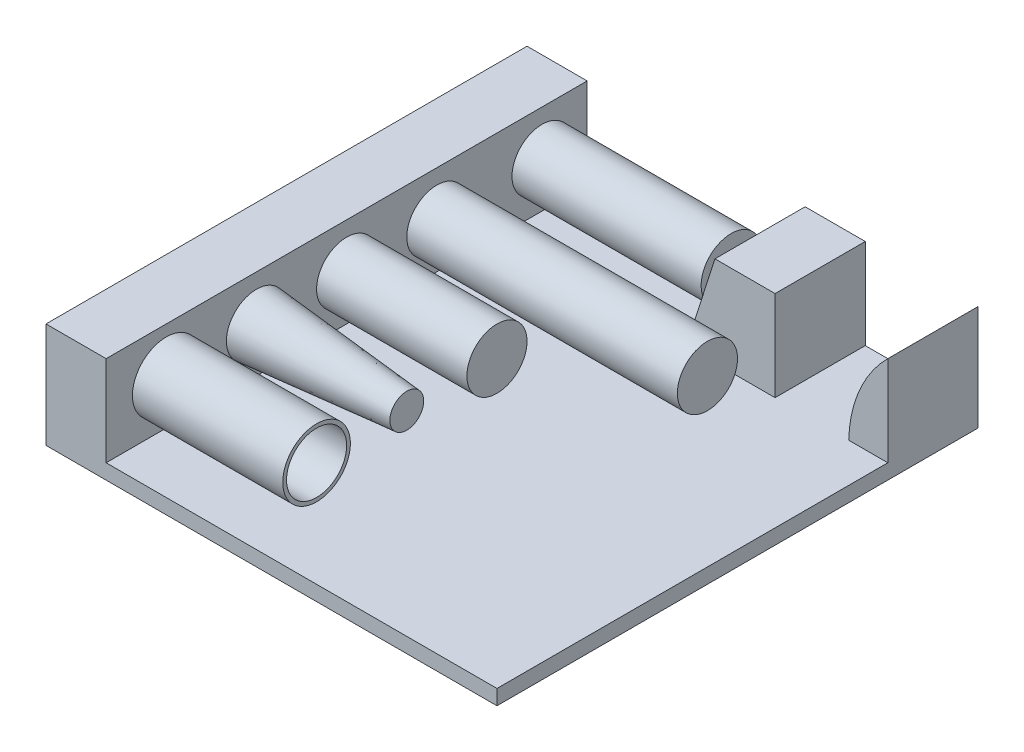
from build123d import *

# Parameters (mm, degrees)
BOSS_EXTRUDE1_DEPTH             = 640
BOSS_EXTRUDE2_DEPTH             = 120
ONE_SIDE_R                      = 40
BOSS_EXTRUDE4_DEPTH             = 251.6
BOTH_SIDES_R                    = 40
BOSS_EXTRUDE5_DEPTH             = 200
BOSS_EXTRUDE5_DIRECTION_2_REACH = 242
SOLID_2_R                       = 40
BOSS_EXTRUDE6_DEPTH             = 200
DRAFT_2_R                       = 40
BOSS_EXTRUDE7_DEPTH             = 200
BOSS_EXTRUDE7_TAPER             = 5
THICKEN_2_R                     = 45
THICKEN_2_R_2                   = 40
EXTRUDE_THIN1_DEPTH             = 200


with BuildPart() as part:
    # Sketch1 → Boss-Extrude1 (new body)
    with BuildSketch(Plane.XY):
        Polygon((-300, 0), (300, 0), (300, 20), (-220, 20), (-220, 140), (-300, 140), align=None)
    extrude(amount=BOSS_EXTRUDE1_DEPTH)

    # Sketch2 → Boss-Extrude2 (add)
    with BuildSketch(Plane.XY):
        with BuildLine():
            Line((300, 140), (300, 20))
            Line((300, 20), (247.956312481, 20))
            ThreePointArc((247.956312481, 20), (262.414199332, 85.015257999), (300, 140))
        make_face()
        Polygon((150, 140), (70, 140), (31.6, 20), (150, 20), align=None)
    extrude(amount=BOSS_EXTRUDE2_DEPTH)

    # One_Side → Boss-Extrude4 (add)
    with BuildSketch(Plane(origin=(-220, 0, 0), x_dir=(0, 0, -1), z_dir=(1, 0, 0))):
        with Locations((-60, 80)):
            Circle(ONE_SIDE_R)
    extrude(amount=BOSS_EXTRUDE4_DEPTH)

    # Both_Sides → Boss-Extrude5 (add)
    with BuildSketch(Plane(origin=(-60, 0, 0), x_dir=(0, 0, -1), z_dir=(1, 0, 0))):
        with Locations((-200, 80)):
            Circle(BOTH_SIDES_R)
    extrude(amount=BOSS_EXTRUDE5_DEPTH)

    # Both_Sides → Boss-Extrude5 direction 2 (add, up to next)
    with BuildSketch(Plane(origin=(-60, 0, 0), x_dir=(0, 0, -1), z_dir=(1, 0, 0)), mode=Mode.PRIVATE) as boss_extrude5_direction_2_sk1:
        with Locations((-200, 80)):
            Circle(BOTH_SIDES_R)
    boss_extrude5_direction_2_tool1 = extrude(boss_extrude5_direction_2_sk1.sketch, amount=-BOSS_EXTRUDE5_DIRECTION_2_REACH, mode=Mode.PRIVATE) - part.part
    add(boss_extrude5_direction_2_tool1.solids().sort_by_distance((-60, 80, 200))[0])

    # Solid 2 → Boss-Extrude6 (add)
    with BuildSketch(Plane(origin=(-220, 0, 0), x_dir=(0, 0, -1), z_dir=(1, 0, 0))):
        with Locations((-320, 80)):
            Circle(SOLID_2_R)
    extrude(amount=BOSS_EXTRUDE6_DEPTH)

    # Draft 2 → Boss-Extrude7 (add)
    with BuildSketch(Plane(origin=(-220, 0, 0), x_dir=(0, 0, -1), z_dir=(1, 0, 0))):
        with Locations((-440, 80)):
            Circle(DRAFT_2_R)
    extrude(amount=BOSS_EXTRUDE7_DEPTH, taper=BOSS_EXTRUDE7_TAPER)

    # Thicken 2 → Extrude-Thin1 (add)
    with BuildSketch(Plane(origin=(-220, 0, 0), x_dir=(0, 0, -1), z_dir=(1, 0, 0))):
        with Locations((-560, 80)):
            Circle(THICKEN_2_R)
        with Locations((-560, 80)):
            Circle(THICKEN_2_R_2, mode=Mode.SUBTRACT)
    extrude(amount=EXTRUDE_THIN1_DEPTH)


solid = part.part
